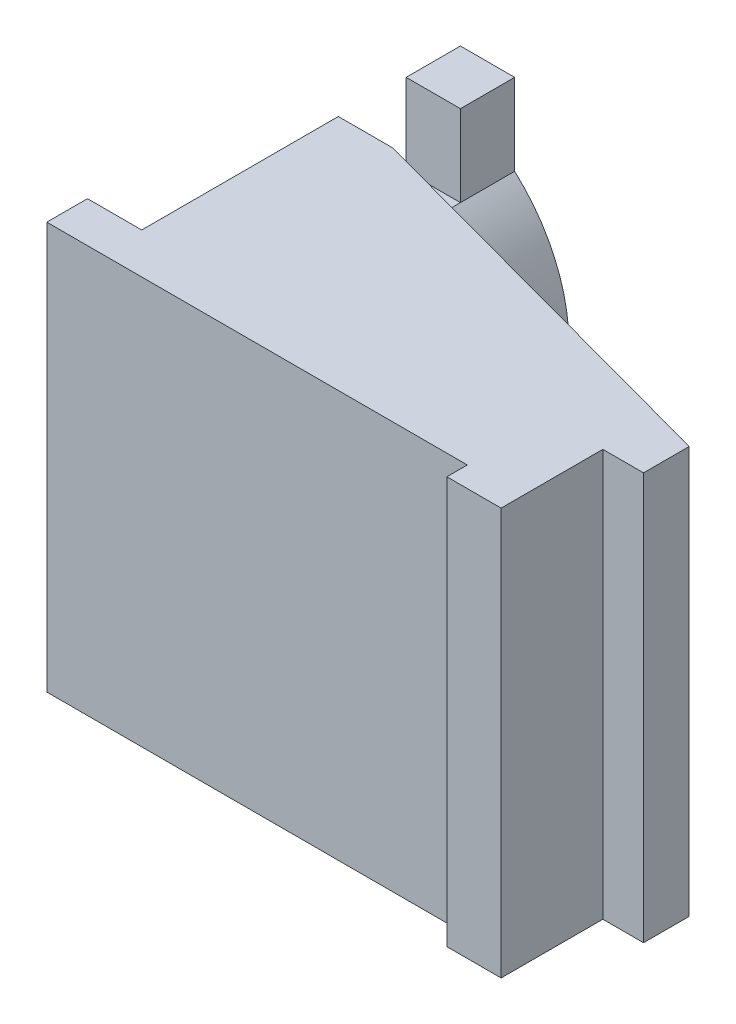
from build123d import *

# Parameters (mm, degrees)
BOSS_EXTRUDE1_DEPTH = 7.5
SKETCH2_W           = 2.5
SKETCH2_H           = 3
CUT_EXTRUDE2_DEPTH  = 20
BOSS_EXTRUDE2_REACH = 16


with BuildPart() as part:
    # Sketch1 → Boss-Extrude1 (new body, symmetric)
    with BuildSketch(Plane(origin=(0, 0, 0), x_dir=(1, 0, 0), z_dir=(0, 1, 0))):
        Polygon((2, 13.245621125), (2, 1.5), (0, 1.5), (0, 0), (15.5, 0), (15.5, -0.754378875), (17.5, -0.754378875), (17.5, 1.128157441), (17.5, 2.995621125), (19, 2.995621125), (19, 4.67916542), (4, 8.745621125), (4, 13.245621125), align=None)
    extrude(amount=BOSS_EXTRUDE1_DEPTH, both=True)

    # Sketch2 → Cut-Extrude2 (cut, through all)
    with BuildSketch(Plane(origin=(0, 0, 0), x_dir=(0, 0, -1), z_dir=(1, 0, 0))):
        with Locations((9.995621125, 6)):
            Rectangle(SKETCH2_W, SKETCH2_H)
        with Locations((9.995621125, -6)):
            Rectangle(SKETCH2_W, SKETCH2_H)
    extrude(amount=CUT_EXTRUDE2_DEPTH, mode=Mode.SUBTRACT)

    # Boss-Extrude2: up to this face of the body (flat: up to its plane)
    boss_extrude2_end = Plane(part.part.faces().sort_by_distance((11.5, 0, -6.712393272))[0])
    # Sketch4 → Boss-Extrude2 (add, up to the picked face)
    with BuildSketch(Plane(origin=(0, 0, -13.245621125), x_dir=(-1, 0, 0), z_dir=(0, 0, -1)), mode=Mode.PRIVATE) as boss_extrude2_sk1:
        with BuildLine():
            Line((-4, 4.5), (-4, -4.5))
            ThreePointArc((-4, -4.5), (-6, 0), (-4, 4.5))
        make_face()
    boss_extrude2_tool1 = split(extrude(boss_extrude2_sk1.sketch, amount=-BOSS_EXTRUDE2_REACH, mode=Mode.PRIVATE), bisect_by=boss_extrude2_end, keep=Keep.BOTH, mode=Mode.PRIVATE)
    add(boss_extrude2_tool1.solids().sort_by_distance((4.812513, 0, -13.245621))[0])


solid = part.part
